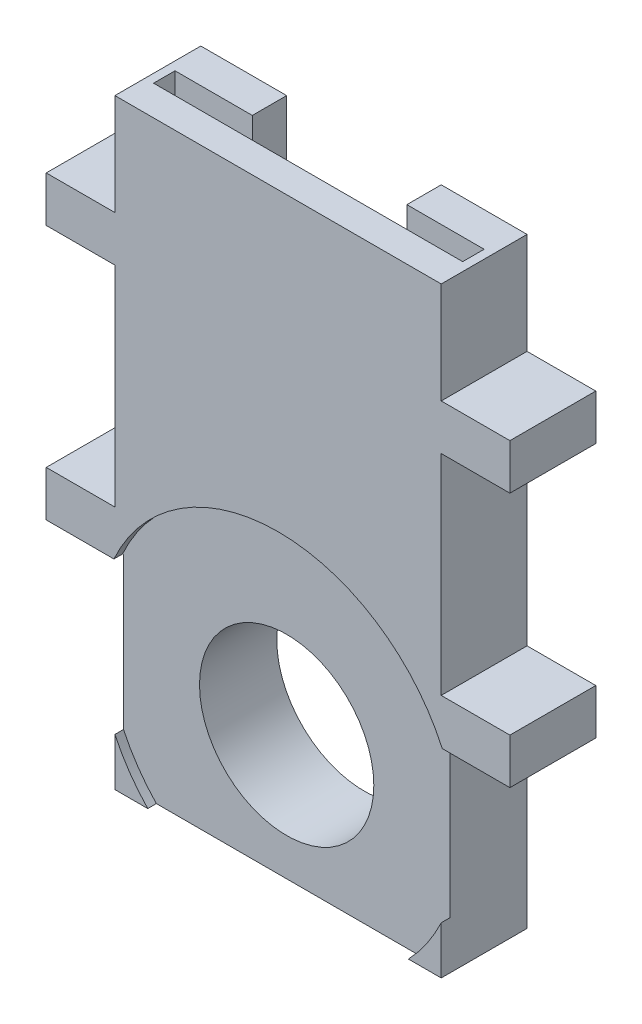
from build123d import *

# Parameters (mm, degrees)
SKETCH2_W           = 19
SKETCH2_H           = 35
BOSS_EXTRUDE1_DEPTH = 5
SKETCH3_W           = 5
SKETCH3_H           = 2.65
BOSS_EXTRUDE2_DEPTH = 13.5
SKETCH3_2_W         = 5
SKETCH3_2_H         = 2.65
BOSS_EXTRUDE3_DEPTH = 13.5
SKETCH4_R           = 5.075
CUT_EXTRUDE1_DEPTH  = 34.35622256
SKETCH5_R           = 10.5
CUT_EXTRUDE2_DEPTH  = 0.5
SKETCH7_W           = 18
SKETCH7_H           = 1.25
CUT_EXTRUDE3_DEPTH  = 22.2
SKETCH8_W           = 9
SKETCH8_H           = 2
CUT_EXTRUDE4_DEPTH  = 19
SKETCH9_W           = 3.4
SKETCH9_H           = 4
CUT_EXTRUDE5_DEPTH  = 1
SKETCH10_W          = 3.4
SKETCH10_H          = 4
CUT_EXTRUDE6_DEPTH  = 1


with BuildPart() as part:
    # Sketch2 → Boss-Extrude1 (new body)
    with BuildSketch(Plane.XY):
        with Locations((-7.329268293, 8.069105691)):
            Rectangle(SKETCH2_W, SKETCH2_H)
    extrude(amount=BOSS_EXTRUDE1_DEPTH)

    # Sketch3 → Boss-Extrude2 (add)
    with BuildSketch(Plane(origin=(-7.329268293, 0, 0), x_dir=(0, 0, -1), z_dir=(1, 0, 0))):
        with Locations((-2.5, 18.344105691)):
            Rectangle(SKETCH3_W, SKETCH3_H)
        with Locations((-2.5, 3.494105691)):
            Rectangle(SKETCH3_W, SKETCH3_H)
    extrude(amount=BOSS_EXTRUDE2_DEPTH)

    # Sketch3_2 → Boss-Extrude3 (add)
    with BuildSketch(Plane(origin=(-7.329268293, 0, 0), x_dir=(0, 0, -1), z_dir=(1, 0, 0))):
        with Locations((-2.5, 18.344105691)):
            Rectangle(SKETCH3_2_W, SKETCH3_2_H)
        with Locations((-2.5, 3.494105691)):
            Rectangle(SKETCH3_2_W, SKETCH3_2_H)
    extrude(amount=-BOSS_EXTRUDE3_DEPTH)

    # Sketch4 → Cut-Extrude1 (cut, through all)
    with BuildSketch(Plane.XY.offset(5)):
        with Locations((-7.329268293, -2.173702028)):
            Circle(SKETCH4_R)
    extrude(amount=-CUT_EXTRUDE1_DEPTH, mode=Mode.SUBTRACT)

    # Sketch5 → Cut-Extrude2 (cut)
    with BuildSketch(Plane.XY.offset(5)):
        with Locations((-7.329268293, -2.173702028)):
            Circle(SKETCH5_R)
    extrude(amount=-CUT_EXTRUDE2_DEPTH, mode=Mode.SUBTRACT)

    # Sketch7 → Cut-Extrude3 (cut)
    with BuildSketch(Plane(origin=(0, 25.569105691, 0), x_dir=(1, 0, 0), z_dir=(0, 1, 0))):
        with Locations((-7.329268293, -2.625)):
            Rectangle(SKETCH7_W, SKETCH7_H)
    extrude(amount=-CUT_EXTRUDE3_DEPTH, mode=Mode.SUBTRACT)

    # Sketch8 → Cut-Extrude4 (cut)
    with BuildSketch(Plane(origin=(0, 25.569105691, 0), x_dir=(1, 0, 0), z_dir=(0, 1, 0))):
        with Locations((-7.329268293, -1)):
            Rectangle(SKETCH8_W, SKETCH8_H)
    extrude(amount=-CUT_EXTRUDE4_DEPTH, mode=Mode.SUBTRACT)

    # Sketch9 → Cut-Extrude5 (cut)
    with BuildSketch(Plane.XZ.offset(-2.169105691)):
        with Locations((-18.829268293, 2.5)):
            Rectangle(SKETCH9_W, SKETCH9_H)
        with Locations((4.170731707, 2.5)):
            Rectangle(SKETCH9_W, SKETCH9_H)
    extrude(amount=-CUT_EXTRUDE5_DEPTH, mode=Mode.SUBTRACT)

    # Sketch10 → Cut-Extrude6 (cut)
    with BuildSketch(Plane.XZ.offset(-17.019105691)):
        with Locations((-18.829268293, 2.5)):
            Rectangle(SKETCH10_W, SKETCH10_H)
        with Locations((4.170731707, 2.5)):
            Rectangle(SKETCH10_W, SKETCH10_H)
    extrude(amount=-CUT_EXTRUDE6_DEPTH, mode=Mode.SUBTRACT)


solid = part.part
